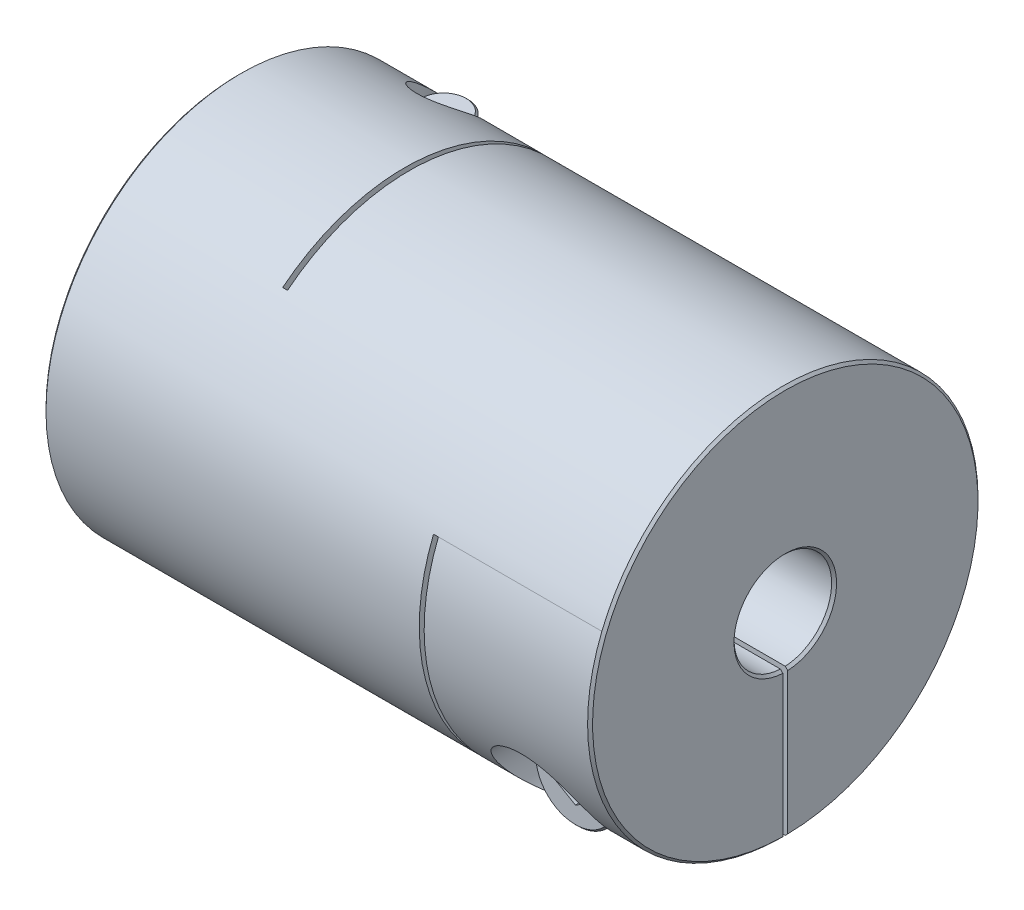
from build123d import *

# Parameters (mm, degrees)
SKETCH1_R                      = 20
BOSS_EXTRUDE1_DEPTH            = 28
SKETCH2_R                      = 5
CUT_EXTRUDE1_DEPTH             = 57
CHAMFER1_SIZE                  = 0.254
SKETCH4_W                      = 0.5
SKETCH4_H                      = 32.5
CUT_EXTRUDE2_DEPTH             = 41
SKETCH7_W                      = 0.5
SKETCH7_H                      = 27.5
CUT_EXTRUDE3_DEPTH             = 41
SKETCH8_W                      = 17
SKETCH8_H                      = 20
CUT_EXTRUDE5_DEPTH             = 0.25
SKETCH13_W                     = 17
SKETCH13_H                     = 20
CUT_EXTRUDE6_DEPTH             = 0.25
CBORE_FOR_M5_SHCS1_D           = 5.5
CBORE_FOR_M5_SHCS1_CBORE_D     = 10
CBORE_FOR_M5_SHCS1_CBORE_DEPTH = 12
CBORE_FOR_M5_SHCS2_D           = 5.5
CBORE_FOR_M5_SHCS2_CBORE_D     = 10
CBORE_FOR_M5_SHCS2_CBORE_DEPTH = 12
SKETCH16_R                     = 4.25
BOSS_EXTRUDE2_DEPTH            = 5
SKETCH17_R                     = 2.5
BOSS_EXTRUDE3_DEPTH            = 22.5
CHAMFER2_SIZE                  = 0.2
CUT_EXTRUDE7_DEPTH             = 1.5
CIRPATTERN1_COUNT              = 2
CIRPATTERN1_ANGLE              = 90


with BuildPart() as part:
    # Sketch1 → Boss-Extrude1 (new body, symmetric)
    with BuildSketch(Plane(origin=(0, 0, 0), x_dir=(0, 0, -1), z_dir=(1, 0, 0))):
        Circle(SKETCH1_R)
    extrude(amount=BOSS_EXTRUDE1_DEPTH, both=True)

    # Sketch2 → Cut-Extrude1 (cut, through all)
    with BuildSketch(Plane(origin=(28, 0, 0), x_dir=(0, 0, -1), z_dir=(1, 0, 0))):
        Circle(SKETCH2_R)
    extrude(amount=-CUT_EXTRUDE1_DEPTH, mode=Mode.SUBTRACT)

    # Chamfer1
    chamfer1_edges = [part.edges().sort_by_distance(p)[0] for p in [
        (-28, 0, 20),
        (28, 0, 20),
        (-28, 0, 5),
        (28, 0, 5),
    ]]
    chamfer(chamfer1_edges, length=CHAMFER1_SIZE)

    # Sketch4 → Cut-Extrude2 (cut, through all)
    with BuildSketch(Plane.XZ.offset(20)):
        with Locations((-10.75, -3.75)):
            Rectangle(SKETCH4_W, SKETCH4_H)
    extrude(amount=-CUT_EXTRUDE2_DEPTH, mode=Mode.SUBTRACT)

    # Sketch7 → Cut-Extrude3 (cut, through all)
    with BuildSketch(Plane(origin=(0, 0, -20), x_dir=(-1, 0, 0), z_dir=(0, 0, -1))):
        with Locations((-10.75, -6.25)):
            Rectangle(SKETCH7_W, SKETCH7_H)
    extrude(amount=-CUT_EXTRUDE3_DEPTH, mode=Mode.SUBTRACT)

    # Sketch8 → Cut-Extrude5 (cut, symmetric)
    with BuildSketch(Plane(origin=(0, 0, 0), x_dir=(1, 0, 0), z_dir=(0, 1, 0))):
        with Locations((-19.5, 10)):
            Rectangle(SKETCH8_W, SKETCH8_H)
    extrude(amount=CUT_EXTRUDE5_DEPTH, both=True, mode=Mode.SUBTRACT)

    # Sketch13 → Cut-Extrude6 (cut, symmetric)
    with BuildSketch(Plane.XY):
        with Locations((19.5, -10)):
            Rectangle(SKETCH13_W, SKETCH13_H)
    extrude(amount=CUT_EXTRUDE6_DEPTH, both=True, mode=Mode.SUBTRACT)

    # CBORE for M5 SHCS1 (through all)
    with Locations(Plane.XZ.offset(20)):
        with Locations((-19.5, -12.496091764)):
            CounterBoreHole(CBORE_FOR_M5_SHCS1_D / 2, CBORE_FOR_M5_SHCS1_CBORE_D / 2, CBORE_FOR_M5_SHCS1_CBORE_DEPTH)

    # CBORE for M5 SHCS2 (through all)
    with Locations(Plane.XY.offset(20)):
        with Locations((19.5, -12.496091764)):
            CounterBoreHole(CBORE_FOR_M5_SHCS2_D / 2, CBORE_FOR_M5_SHCS2_CBORE_D / 2, CBORE_FOR_M5_SHCS2_CBORE_DEPTH)


with BuildPart() as body_2:
    # Sketch16 → Boss-Extrude2 (new body)
    with BuildSketch(Plane.XY.offset(8)):
        with Locations((19.5, -12.496091764)):
            Circle(SKETCH16_R)
    extrude(amount=BOSS_EXTRUDE2_DEPTH)

    # Sketch17 → Boss-Extrude3 (add)
    with BuildSketch(Plane(origin=(0, 0, 8), x_dir=(-1, 0, 0), z_dir=(0, 0, -1))):
        with Locations(Location((-19.5, -12.496091764, 0), (0, 0, 180))):  # turned: the seam where the file's is
            Circle(SKETCH17_R)
    extrude(amount=BOSS_EXTRUDE3_DEPTH)

    # Chamfer2
    chamfer2_edges = [body_2.edges().sort_by_distance(p)[0] for p in [
        (15.25, -12.496091764, 8),
        (15.25, -12.496091764, 13),
        (17, -12.496091764, -14.5),
    ]]
    chamfer(chamfer2_edges, length=CHAMFER2_SIZE)

    # Sketch18 → Cut-Extrude7 (cut)
    with BuildSketch(Plane.XY.offset(13)):
        Polygon((19.5, -14.805492841), (21.5, -13.650792302), (21.5, -11.341391226), (19.5, -10.186690687), (17.5, -11.341391226), (17.5, -13.650792302), align=None)
    extrude(amount=-CUT_EXTRUDE7_DEPTH, mode=Mode.SUBTRACT)


with BuildPart() as body_3:
    # Mirror1: mirrored copy
    add(body_2.part.mirror(Plane(origin=(0, 0, 0), x_dir=(0, 0, 1), z_dir=(1, 0, 0))))


with BuildPart() as cirpattern1_1:
    # CirPattern1: pattern copy
    add(body_3.part.rotate(Axis((0, 0, 0), (1, 0, 0)), 1 * CIRPATTERN1_ANGLE / (CIRPATTERN1_COUNT - 1)))


solid = Compound([part.part, body_2.part, cirpattern1_1.part])
